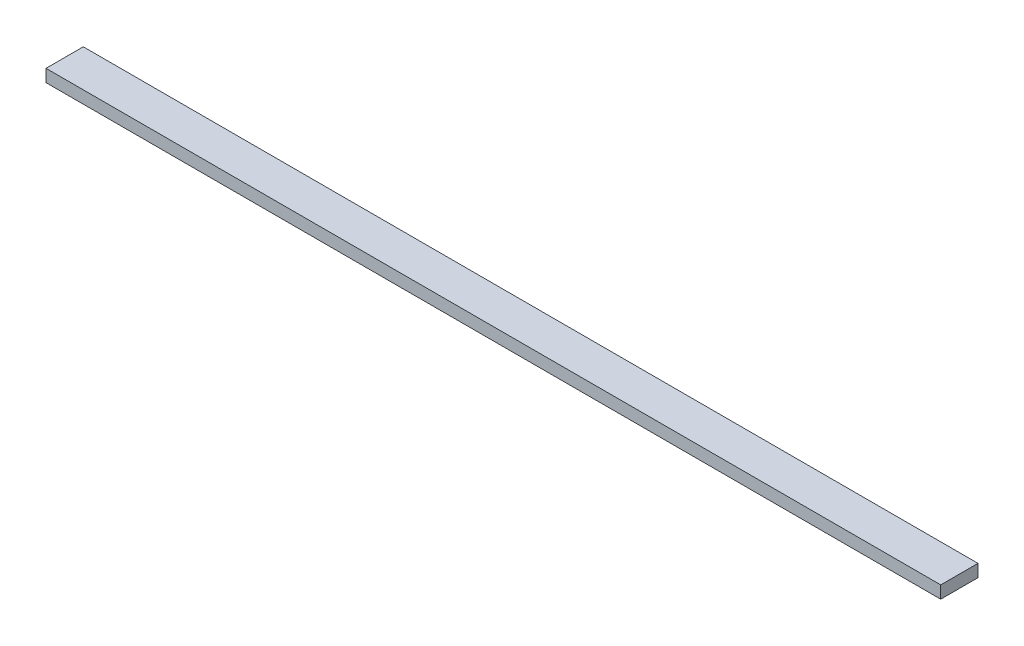
from build123d import *

# Parameters (mm, degrees)
SKETCH1_W           = 914.4
SKETCH1_H           = 38.1
BOSS_EXTRUDE1_DEPTH = 12.7


with BuildPart() as part:
    # Sketch1 → Boss-Extrude1 (new body)
    with BuildSketch(Plane(origin=(0, 0, 0), x_dir=(1, 0, 0), z_dir=(0, 1, 0))):
        with Locations((457.2, 19.05)):
            Rectangle(SKETCH1_W, SKETCH1_H)
    extrude(amount=BOSS_EXTRUDE1_DEPTH)


solid = part.part
